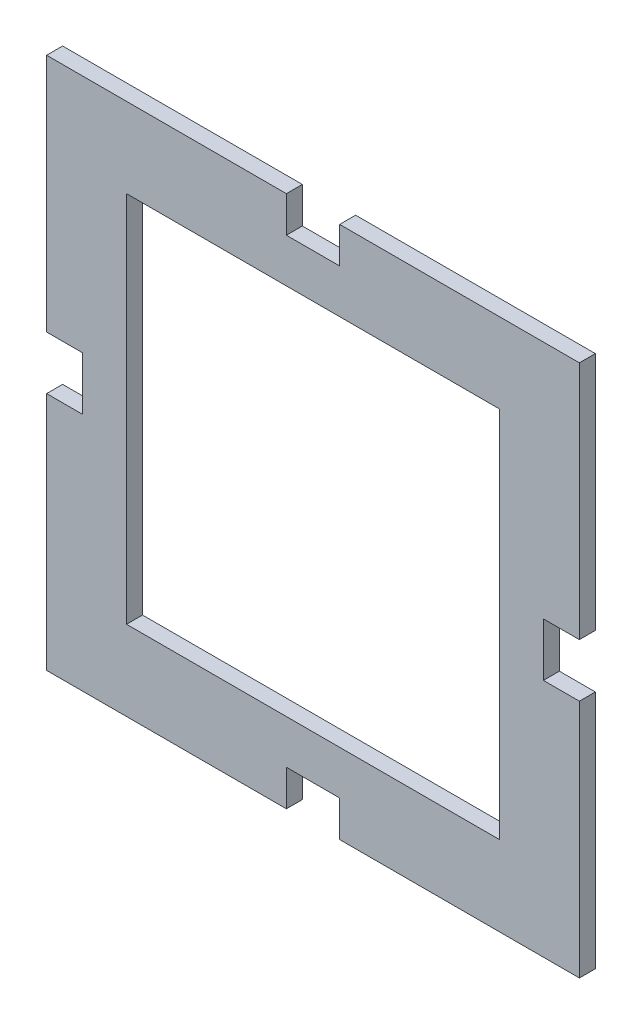
from build123d import *

# Parameters (mm, degrees)
SKETCH1_W           = 70
SKETCH1_H           = 70
BOSS_EXTRUDE1_DEPTH = 3


with BuildPart() as part:
    # Sketch1 → Boss-Extrude1 (new body)
    with BuildSketch(Plane.XY):
        Polygon((-5, 50), (-50, 50), (-50, 5), (-43.24, 5), (-43.24, -5), (-50, -5), (-50, -50), (-5, -50), (-5, -43.24), (5, -43.24), (5, -50), (50, -50), (50, -5), (43.24, -5), (43.24, 5), (50, 5), (50, 50), (5, 50), (5, 43.24), (-5, 43.24), align=None)
        Rectangle(SKETCH1_W, SKETCH1_H, mode=Mode.SUBTRACT)
    extrude(amount=BOSS_EXTRUDE1_DEPTH)


solid = part.part
